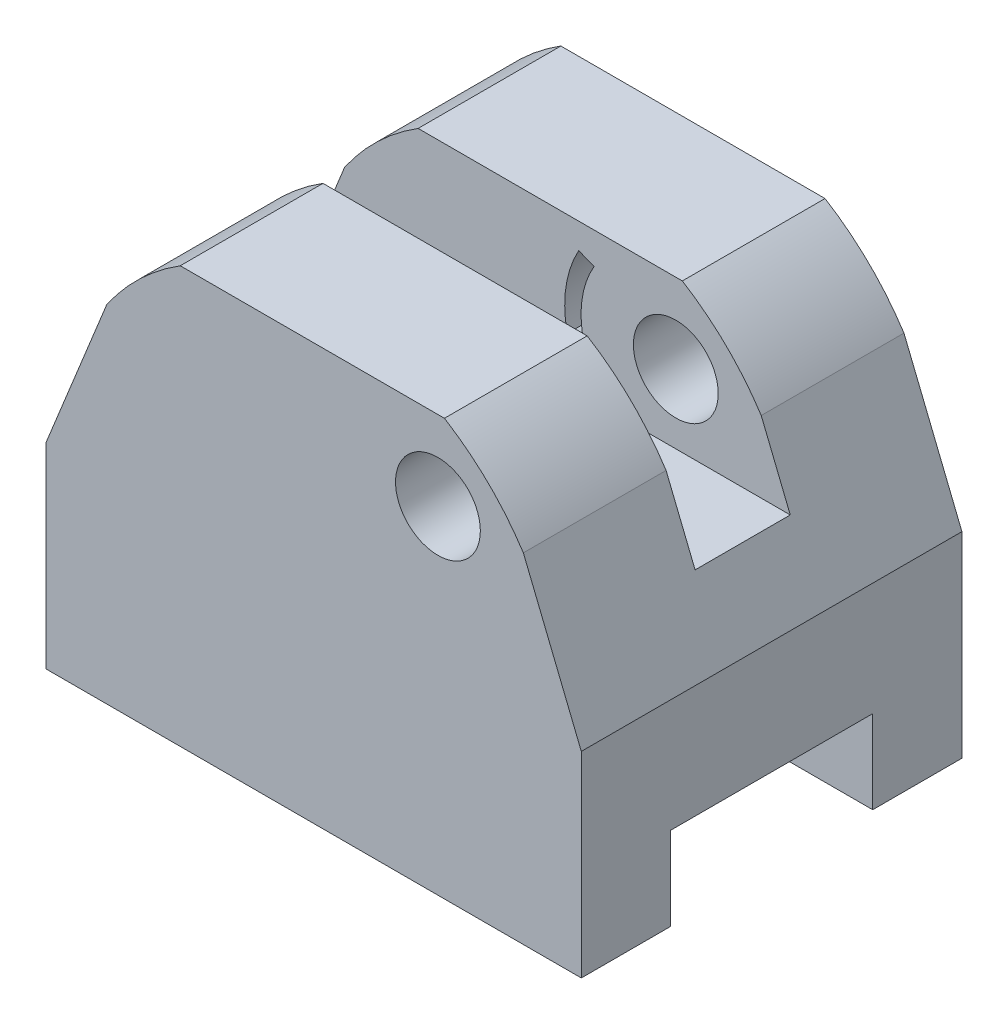
from build123d import *

# Parameters (mm, degrees)
SKETCH1_W           = 64
SKETCH1_H           = 33
BOSS_EXTRUDE2_DEPTH = 90
SKETCH5_W           = 34
SKETCH5_H           = 14
CUT_EXTRUDE1_DEPTH  = 91
SKETCH7_W           = 90
SKETCH7_H           = 64
BOSS_EXTRUDE3_DEPTH = 37
SKETCH9_W           = 16
SKETCH9_H           = 25
CUT_EXTRUDE2_DEPTH  = 91
CUT_EXTRUDE3_DEPTH  = 65
CUT_EXTRUDE4_DEPTH  = 65
SKETCH12_R          = 4.563258517
CUT_EXTRUDE5_DEPTH  = 65
SKETCH13_R          = 3.396180785
CUT_EXTRUDE7_DEPTH  = 4
SKETCH14_R          = 7.131807436
CUT_EXTRUDE8_DEPTH  = 65
CUT_EXTRUDE9_START  = -17
CUT_EXTRUDE9_DEPTH  = 30


with BuildPart() as part:
    # Sketch1 → Boss-Extrude2 (new body)
    with BuildSketch(Plane(origin=(0, 0, 0), x_dir=(0, 0, -1), z_dir=(1, 0, 0))):
        Rectangle(SKETCH1_W, SKETCH1_H)
    extrude(amount=BOSS_EXTRUDE2_DEPTH)

    # Sketch5 → Cut-Extrude1 (cut, through all)
    with BuildSketch(Plane.ZY):
        with Locations((0, -9.5)):
            Rectangle(SKETCH5_W, SKETCH5_H)
    extrude(amount=-CUT_EXTRUDE1_DEPTH, mode=Mode.SUBTRACT)

    # Sketch7 → Boss-Extrude3 (add)
    with BuildSketch(Plane(origin=(0, 16.5, 0), x_dir=(1, 0, 0), z_dir=(0, 1, 0))):
        with Locations((45, 0)):
            Rectangle(SKETCH7_W, SKETCH7_H)
    extrude(amount=BOSS_EXTRUDE3_DEPTH)

    # Sketch9 → Cut-Extrude2 (cut, through all)
    with BuildSketch(Plane.ZY):
        with Locations((0, 41)):
            Rectangle(SKETCH9_W, SKETCH9_H)
    extrude(amount=-CUT_EXTRUDE2_DEPTH, mode=Mode.SUBTRACT)

    # Sketch10 → Cut-Extrude3 (cut, through all)
    with BuildSketch(Plane.XY.offset(32)):
        Polygon((0, 16.5), (15, 53.5), (0, 53.5), align=None)
        Polygon((90, 53.5), (90, 16.5), (75, 53.5), align=None)
    extrude(amount=-CUT_EXTRUDE3_DEPTH, mode=Mode.SUBTRACT)

    # Sketch11 → Cut-Extrude4 (cut, through all)
    with BuildSketch(Plane.XY.offset(32)):
        with BuildLine():
            Line((22.559269827, 53.5), (15, 53.5))
            Line((15, 53.5), (10.196218084, 41.650671273))
            ThreePointArc((10.196218084, 41.650671273), (15.770987206, 48.208398087), (22.559269827, 53.5))
        make_face()
        with BuildLine():
            Line((80.252850536, 40.542968678), (75, 53.5))
            Line((75, 53.5), (66.982723611, 53.5))
            ThreePointArc((66.982723611, 53.5), (74.341930784, 47.763126364), (80.252850536, 40.542968678))
        make_face()
    extrude(amount=-CUT_EXTRUDE4_DEPTH, mode=Mode.SUBTRACT)

    # Sketch12 → Cut-Extrude5 (cut, through all)
    with BuildSketch(Plane(origin=(0, 0, -32), x_dir=(-1, 0, 0), z_dir=(0, 0, -1))):
        with Locations((-65.890311292, 40.12330388)):
            Circle(SKETCH12_R)
    extrude(amount=-CUT_EXTRUDE5_DEPTH, mode=Mode.SUBTRACT)

    # Sketch13 → Cut-Extrude7 (cut)
    with BuildSketch(Plane(origin=(0, 28.5, 0), x_dir=(1, 0, 0), z_dir=(0, 1, 0))):
        with Locations((18.559847102, 1.303256126)):
            Circle(SKETCH13_R)
    extrude(amount=-CUT_EXTRUDE7_DEPTH, mode=Mode.SUBTRACT)

    # Sketch14 → Cut-Extrude8 (cut, through all)
    with BuildSketch(Plane.XY.offset(32)):
        with Locations((65.890311292, 40.12330388)):
            Circle(SKETCH14_R)
    extrude(amount=-CUT_EXTRUDE8_DEPTH, mode=Mode.SUBTRACT)

    # Sketch15 → Cut-Extrude9 (cut)
    with BuildSketch(Plane.XY.offset(32).offset(CUT_EXTRUDE9_START)):
        with BuildLine():
            Line((52.144239181, 48.178611287), (49.568050992, 49.212876474))
            ThreePointArc((49.568050992, 49.212876474), (47.410527131, 42.86813331), (47.630804887, 36.170211787))
            Line((47.630804887, 36.170211787), (50.191024462, 37.407632885))
            ThreePointArc((50.191024462, 37.407632885), (50.21355191, 42.966135424), (52.144239181, 48.178611287))
        make_face()
    extrude(amount=-CUT_EXTRUDE9_DEPTH, mode=Mode.SUBTRACT)


solid = part.part
